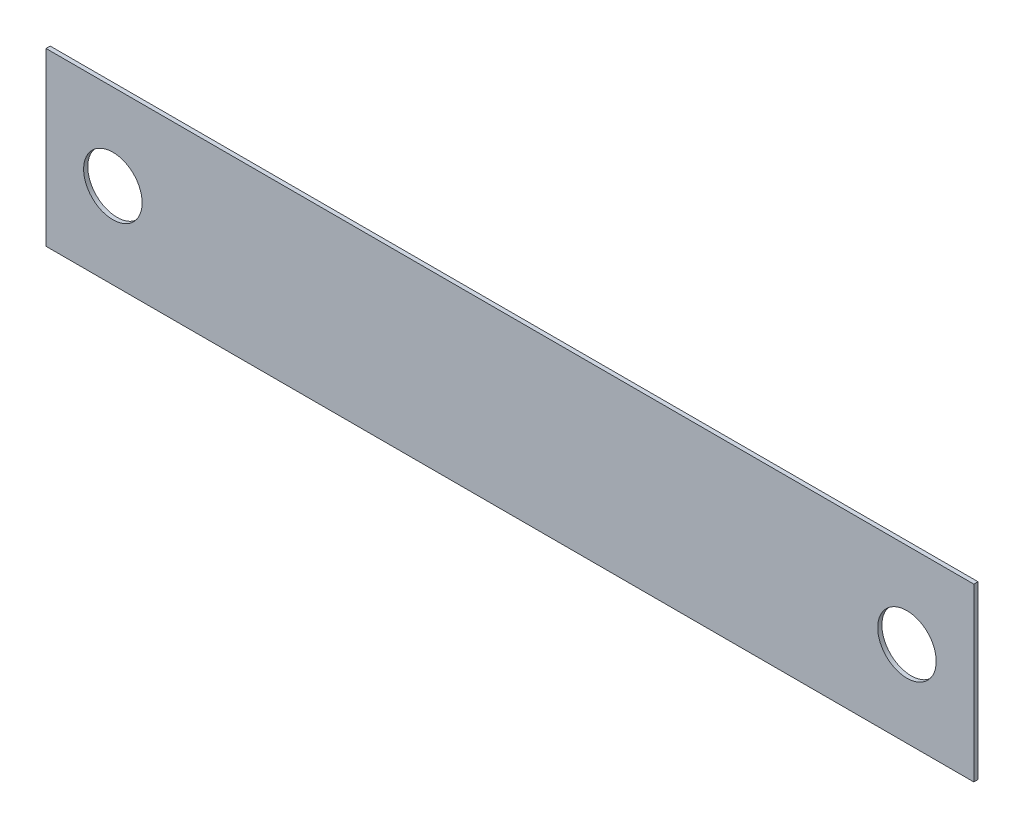
from build123d import *

# Parameters (mm, degrees)
SKETCH1_W           = 111
SKETCH1_H           = 20.5
SKETCH1_R           = 3.5
BOSS_EXTRUDE1_DEPTH = 0.5


with BuildPart() as part:
    # Sketch1 → Boss-Extrude1 (new body)
    with BuildSketch(Plane.XY):
        with Locations((55.5, 10.25)):
            Rectangle(SKETCH1_W, SKETCH1_H)
        with Locations((8, 10.25)):
            Circle(SKETCH1_R, mode=Mode.SUBTRACT)
        with Locations((103, 10.25)):
            Circle(SKETCH1_R, mode=Mode.SUBTRACT)
    extrude(amount=BOSS_EXTRUDE1_DEPTH)


solid = part.part
